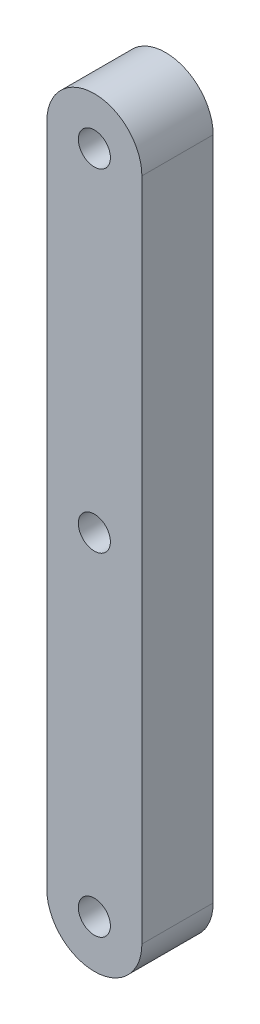
from build123d import *

# Parameters (mm, degrees)
SKETCH1_R           = 1.7145
BOSS_EXTRUDE1_DEPTH = 7.62
SKETCH2_R           = 1.7145
CUT_EXTRUDE1_DEPTH  = 10.16


with BuildPart() as part:
    # Sketch1 → Boss-Extrude1 (new body)
    with BuildSketch(Plane.XY):
        with BuildLine():
            Line((0, 0), (0, 71.12))
            ThreePointArc((0, 71.12), (5.08, 76.2), (10.16, 71.12))
            Line((10.16, 71.12), (10.16, 0))
            ThreePointArc((10.16, 0), (5.08, -5.08), (0, 0))
        make_face()
        with Locations((5.08, 71.12)):
            Circle(SKETCH1_R, mode=Mode.SUBTRACT)
        with Locations((5.08, 0)):
            Circle(SKETCH1_R, mode=Mode.SUBTRACT)
    extrude(amount=BOSS_EXTRUDE1_DEPTH)

    # Sketch2 → Cut-Extrude1 (cut)
    with BuildSketch(Plane.XY.offset(7.62)):
        with Locations((5.08, 35.56)):
            Circle(SKETCH2_R)
    extrude(amount=-CUT_EXTRUDE1_DEPTH, mode=Mode.SUBTRACT)


solid = part.part
